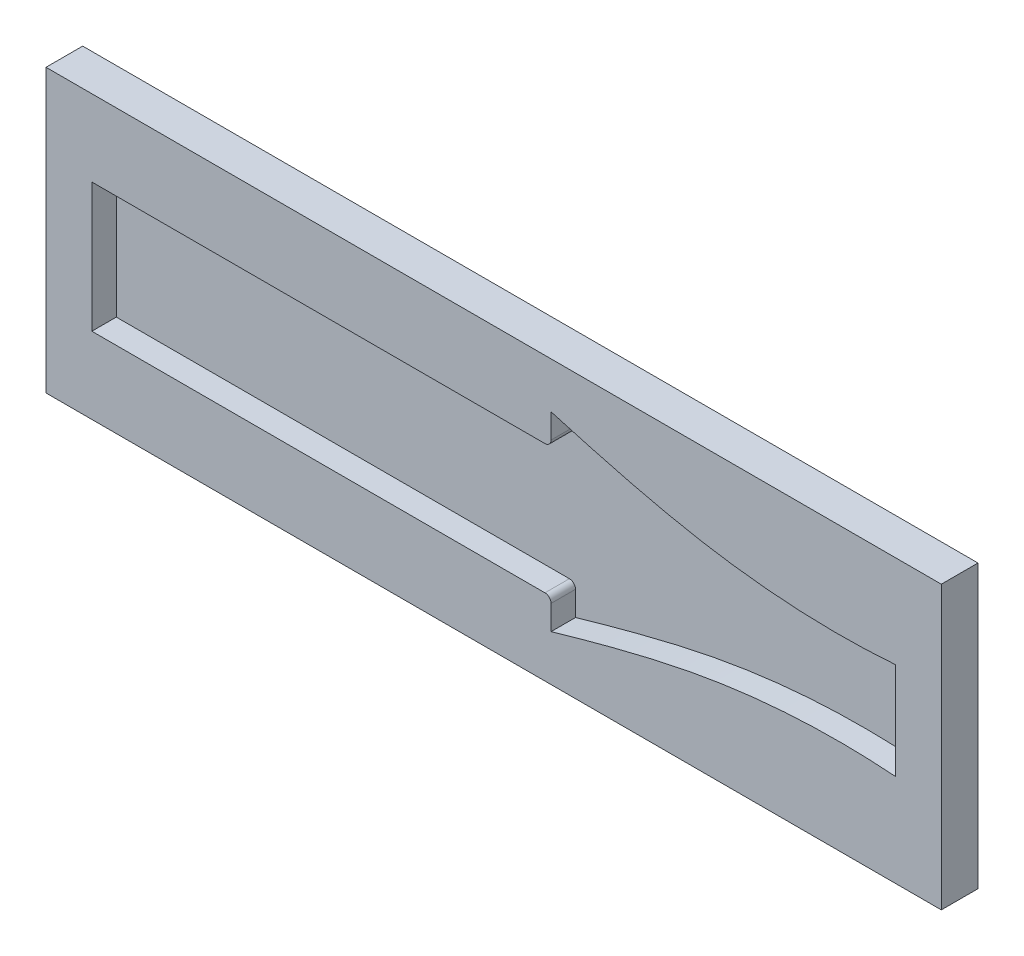
from build123d import *

# Parameters (mm, degrees)
SKETCH3_W           = 146.45
SKETCH3_H           = 46.142690012
BOSS_EXTRUDE1_DEPTH = 10
SKETCH5_W           = 146.45
SKETCH5_H           = 46.142690012
BOSS_EXTRUDE2_DEPTH = 6
BOSS_EXTRUDE3_DEPTH = 4


with BuildPart() as part:
    # Sketch3 → Boss-Extrude1 (new body)
    with BuildSketch(Plane.XY):
        with Locations((221.625, 0)):
            Rectangle(SKETCH3_W, SKETCH3_H)
        with BuildLine():
            Line((231.014073024, 15.571345006), (155.9, 15.571345006))
            Line((155.9, 15.571345006), (155.9, -15.571345006))
            Line((155.9, -15.571345006), (231.014073024, -15.571345006))
            add(Edge.make_bspline(
                [(231.014073024, -15.571345006), (235.603926114, -14.253380454), (240.202907461, -12.969220406), (247.161881801, -11.267037426), (249.489374332, -10.737991357), (254.165641768, -9.787213526), (256.514768348, -9.366822526), (263.601279745, -8.301427441), (268.338086531, -7.848826201), (275.456073059, -7.568289481), (277.831222276, -7.541362556), (282.586677642, -7.625574787), (284.967063297, -7.738842578), (287.35, -7.920409313)],
                knots=[0, 0, 0, 0, 0.25, 0.25, 0.375, 0.375, 0.5, 0.5, 0.75, 0.75, 0.875, 0.875, 1, 1, 1, 1], degree=3))
            Line((287.35, -7.920409313), (287.35, 7.920409313))
            add(Edge.make_bspline(
                [(287.35, 7.920409313), (284.969156465, 7.739002066), (282.587135429, 7.625484493), (277.820616166, 7.541273347), (275.436154733, 7.568458416), (268.279260355, 7.852389695), (263.532649453, 8.309357778), (256.45099394, 9.377629241), (254.104302816, 9.79880166), (249.438001237, 10.749341419), (247.117365, 11.277508342), (240.182218106, 12.975127096), (235.594114602, 14.256197804), (231.014073024, 15.571345006)],
                knots=[0, 0, 0, 0, 0.125, 0.125, 0.25, 0.25, 0.5, 0.5, 0.625, 0.625, 0.75, 0.75, 1, 1, 1, 1], degree=3))
        make_face(mode=Mode.SUBTRACT)
    extrude(amount=BOSS_EXTRUDE1_DEPTH)

    # Sketch5 → Boss-Extrude2 (add)
    with BuildSketch(Plane.XY):
        with Locations((221.625, 0)):
            Rectangle(SKETCH5_W, SKETCH5_H)
    extrude(amount=BOSS_EXTRUDE2_DEPTH)

    # Sketch6 → Boss-Extrude3 (add)
    with BuildSketch(Plane.XY.offset(6)):
        with BuildLine():
            Line((231.014073024, 15.571345006), (155.9, 15.571345006))
            Line((155.9, 15.571345006), (155.9, 10.571345006))
            Line((155.9, 10.571345006), (230.014073024, 10.571345006))
            ThreePointArc((230.014073024, 10.571345006), (230.721179805, 10.864238225), (231.014073024, 11.571345006))
            Line((231.014073024, 11.571345006), (231.014073024, 15.571345006))
        make_face()
        with BuildLine():
            Line((231.014073024, -15.571345006), (155.9, -15.571345006))
            Line((155.9, -15.571345006), (155.9, -10.571345006))
            Line((155.9, -10.571345006), (230.014073024, -10.571345006))
            ThreePointArc((230.014073024, -10.571345006), (230.721179805, -10.864238225), (231.014073024, -11.571345006))
            Line((231.014073024, -11.571345006), (231.014073024, -15.571345006))
        make_face()
    extrude(amount=BOSS_EXTRUDE3_DEPTH)

    # SurfaceCut2
    split(bisect_by=Plane.XY.offset(4), keep=Keep.TOP)


solid = part.part
